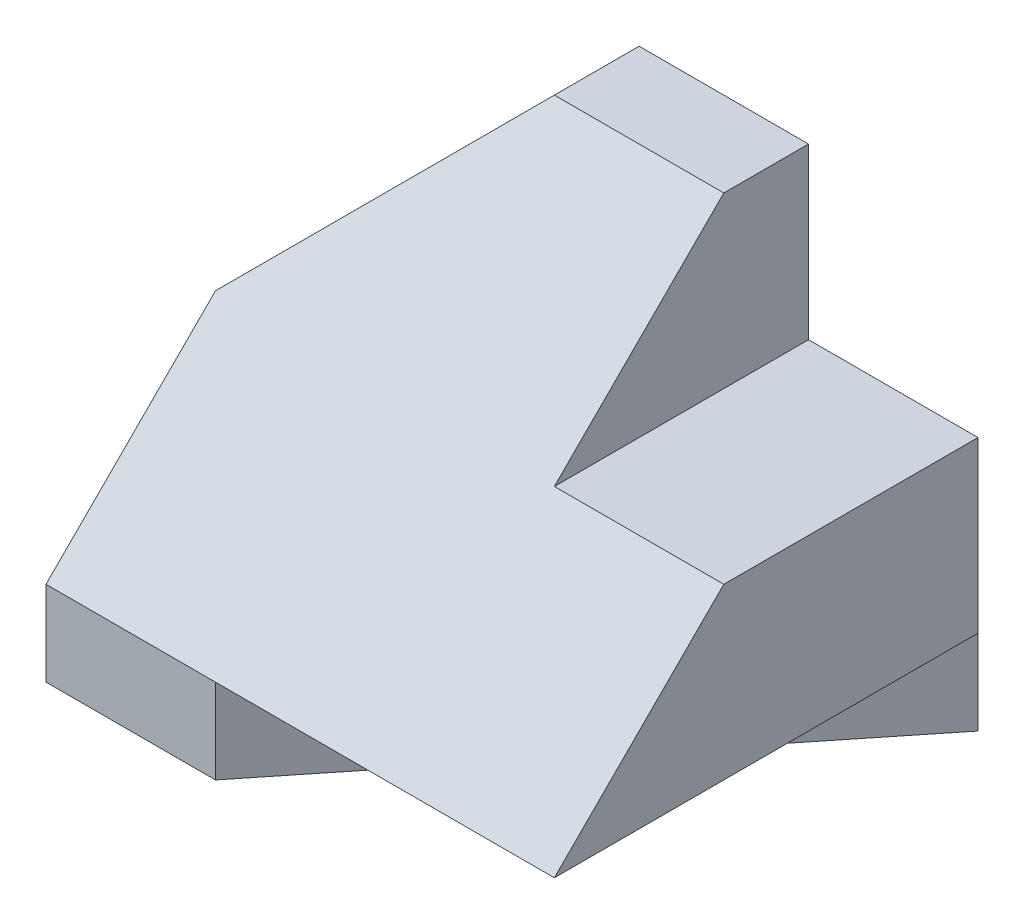
from build123d import *

# Parameters (mm, degrees)
SKETCH5_W           = 30
SKETCH5_H           = 25
BOSS_EXTRUDE2_DEPTH = 25
CUT_EXTRUDE2_DEPTH  = 30
SKETCH7_W           = 5
SKETCH7_H           = 15
CUT_EXTRUDE3_DEPTH  = 10
CUT_EXTRUDE4_DEPTH  = 5
SKETCH12_W          = 10
SKETCH12_H          = 10
CUT_EXTRUDE7_DEPTH  = 10
CUT_EXTRUDE8_DEPTH  = 10
CUT_EXTRUDE9_DEPTH  = 20
CUT_EXTRUDE12_DEPTH = 5


with BuildPart() as part:
    # Sketch5 → Boss-Extrude2 (new body)
    with BuildSketch(Plane.XY):
        with Locations((15, 12.5)):
            Rectangle(SKETCH5_W, SKETCH5_H)
    extrude(amount=BOSS_EXTRUDE2_DEPTH)

    # Sketch6 → Cut-Extrude2 (cut)
    with BuildSketch(Plane.ZY):
        Polygon((25, 25), (25, 5), (5, 25), align=None)
    extrude(amount=-CUT_EXTRUDE2_DEPTH, mode=Mode.SUBTRACT)

    # Sketch7 → Cut-Extrude3 (cut)
    with BuildSketch(Plane.ZY):
        with Locations((2.5, 7.5)):
            Rectangle(SKETCH7_W, SKETCH7_H)
    extrude(amount=-CUT_EXTRUDE3_DEPTH, mode=Mode.SUBTRACT)

    # Sketch9 → Cut-Extrude4 (cut)
    with BuildSketch(Plane(origin=(0, 0, 0), x_dir=(-1, 0, 0), z_dir=(0, -1, 0))):
        Polygon((0, -25), (0, -5), (-10, -5), align=None)
    extrude(amount=-CUT_EXTRUDE4_DEPTH, mode=Mode.SUBTRACT)

    # Sketch12 → Cut-Extrude7 (cut)
    with BuildSketch(Plane(origin=(0, 25, 0), x_dir=(1, 0, 0), z_dir=(0, 1, 0))):
        with Locations((25, -5)):
            Rectangle(SKETCH12_W, SKETCH12_H)
    extrude(amount=-CUT_EXTRUDE7_DEPTH, mode=Mode.SUBTRACT)

    # Sketch13 → Cut-Extrude8 (cut)
    with BuildSketch(Plane(origin=(30, 0, 0), x_dir=(0, 0, -1), z_dir=(1, 0, 0))):
        Polygon((-10, 15), (-15, 15), (-10, 20), align=None)
    extrude(amount=-CUT_EXTRUDE8_DEPTH, mode=Mode.SUBTRACT)

    # Sketch14 → Cut-Extrude9 (cut)
    with BuildSketch(Plane(origin=(0, 0, 0), x_dir=(-1, 0, 0), z_dir=(0, 0, -1))):
        Polygon((0, 25), (-10, 25), (0, 15), align=None)
    extrude(amount=-CUT_EXTRUDE9_DEPTH, mode=Mode.SUBTRACT)

    # Sketch15 → Cut-Extrude12 (cut)
    with BuildSketch(Plane(origin=(0, 0, 0), x_dir=(-1, 0, 0), z_dir=(0, -1, 0))):
        Polygon((-30, 0), (-30, -25), (-10, -25), align=None)
    extrude(amount=-CUT_EXTRUDE12_DEPTH, mode=Mode.SUBTRACT)


solid = part.part
